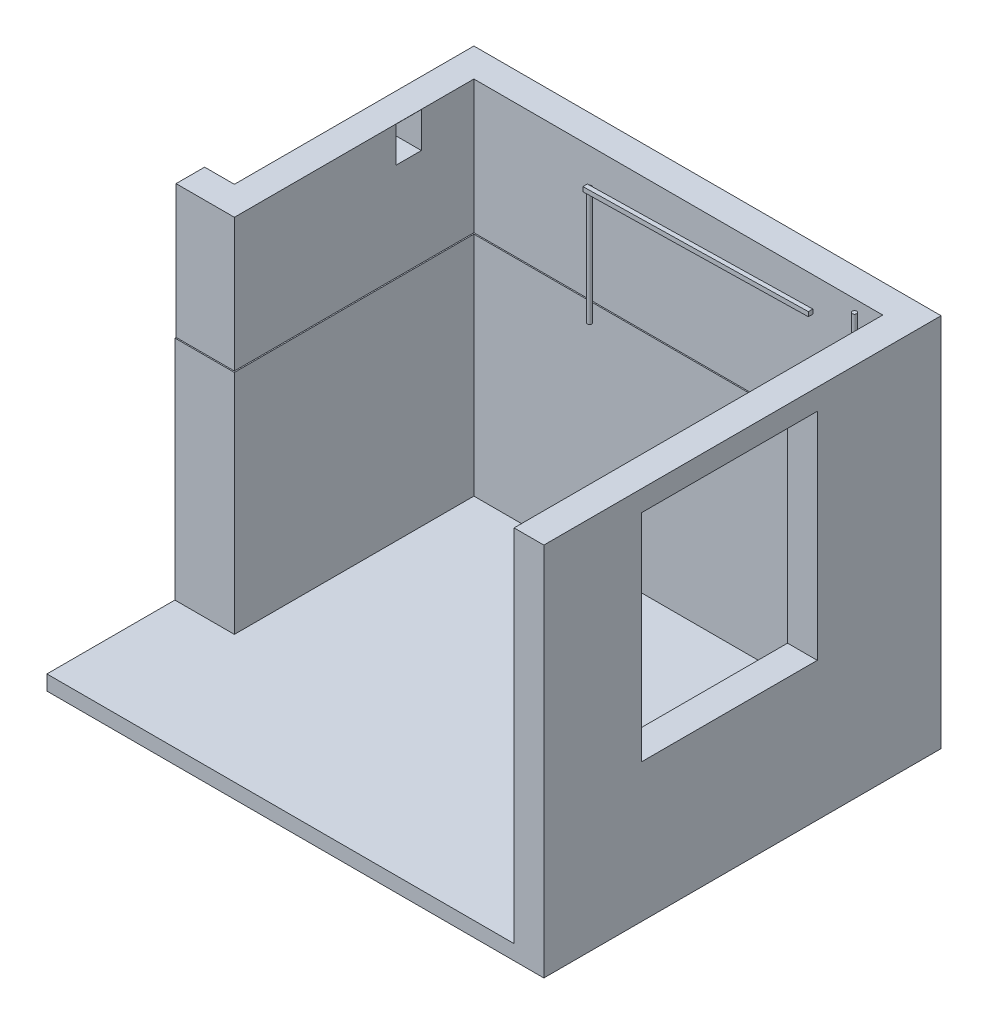
from build123d import *

# Parameters (mm, degrees)
EXTRUDE_1_DEPTH     = 2420
EXTRUDE_2_DEPTH     = 100
SKETCH_3_W          = 3340
SKETCH_3_H          = 2520
CUT_EXTRUDE_1_DEPTH = 200
SKETCH_4_W          = 170
SKETCH_4_H          = 239
CUT_EXTRUDE_2_DEPTH = 200
CUT_EXTRUDE_3_DEPTH = 895
SKETCH_6_R          = 15
EXTRUDE_3_DEPTH     = 790
SKETCH_7_R          = 15
EXTRUDE_4_DEPTH     = 2420
SKETCH_10_W         = 190
SKETCH_10_H         = 140
EXTRUDE_6_DEPTH     = 230
EXTRUDE_7_DEPTH     = 30
SKETCH_13_W         = 1180
SKETCH_13_H         = 1450
CUT_EXTRUDE_4_DEPTH = 400


with BuildPart() as part:
    # Эскиз1 → Бобышка-Вытянуть1 (new body)
    with BuildSketch(Plane(origin=(0, 0, 0), x_dir=(1, 0, 0), z_dir=(0, 1, 0))):
        Polygon((0, 0), (0, 1610), (2740, 1610), (2740, -860), (-400, -860), (-400, -1060), (2940, -1060), (2940, 1810), (-200, 1810), (-200, 200), (-400, 200), (-400, 0), align=None)
    extrude(amount=EXTRUDE_1_DEPTH)

    # Эскиз2 → Бобышка-Вытянуть2 (add)
    with BuildSketch(Plane.XZ):
        Polygon((-400, 1060), (2940, 1060), (2940, -1810), (-200, -1810), (-200, -200), (-400, -200), align=None)
    extrude(amount=EXTRUDE_2_DEPTH)

    # Эскиз3 → Вырез-Вытянуть1 (cut)
    with BuildSketch(Plane.XY.offset(1060)):
        with Locations((1270, 1160)):
            Rectangle(SKETCH_3_W, SKETCH_3_H)
    extrude(amount=-CUT_EXTRUDE_1_DEPTH, mode=Mode.SUBTRACT)

    # Эскиз4 → Вырез-Вытянуть2 (cut)
    with BuildSketch(Plane(origin=(0, 0, 0), x_dir=(0, 0, -1), z_dir=(1, 0, 0))):
        with Locations((1180, 2299.5)):
            Rectangle(SKETCH_4_W, SKETCH_4_H)
    extrude(amount=-CUT_EXTRUDE_2_DEPTH, mode=Mode.SUBTRACT)

    # Эскиз5 → Вырез-Вытянуть3 (cut)
    with BuildSketch(Plane(origin=(0, 2420, 0), x_dir=(1, 0, 0), z_dir=(0, 1, 0))):
        Polygon((-400, 8), (-8, 8), (-8, 1618), (2740, 1618), (2740, 1610), (0, 1610), (0, 0), (-400, 0), align=None)
    extrude(amount=-CUT_EXTRUDE_3_DEPTH, mode=Mode.SUBTRACT)

    # Эскиз7 → Бобышка-Вытянуть4 (add)
    with BuildSketch(Plane(origin=(0, 2420, 0), x_dir=(1, 0, 0), z_dir=(0, 1, 0))):
        with Locations((2630, 1538)):
            Circle(SKETCH_7_R)
    extrude(amount=-EXTRUDE_4_DEPTH)

    # Эскиз13 → Вырез-Вытянуть4 (cut)
    with BuildSketch(Plane(origin=(2940, 0, 0), x_dir=(0, 0, -1), z_dir=(1, 0, 0))):
        with Locations((388, 1555)):
            Rectangle(SKETCH_13_W, SKETCH_13_H)
    extrude(amount=-CUT_EXTRUDE_4_DEPTH, mode=Mode.SUBTRACT)


with BuildPart() as body_2:
    # Эскиз6 → Бобышка-Вытянуть3 (new body)
    with BuildSketch(Plane(origin=(0, 2235, 0), x_dir=(1, 0, 0), z_dir=(0, 1, 0))):
        with Locations((824.5, 1563)):
            Circle(SKETCH_6_R)
    extrude(amount=-EXTRUDE_3_DEPTH)

    # Эскиз12 → Бобышка-Вытянуть7 (add)
    with BuildSketch(Plane.XY.offset(-1563)):
        Polygon((809.5, 2215), (2325, 2245), (2325, 2275), (809.5, 2245), align=None)
    extrude(amount=EXTRUDE_7_DEPTH)


with BuildPart() as body_3:
    # Эскиз10 → Бобышка-Вытянуть6 (new body)
    with BuildSketch(Plane(origin=(0, 1535, 0), x_dir=(1, 0, 0), z_dir=(0, 1, 0))):
        with Locations((2375, 1528)):
            Rectangle(SKETCH_10_W, SKETCH_10_H)
    extrude(amount=EXTRUDE_6_DEPTH)


solid = Compound([part.part, body_2.part, body_3.part])
